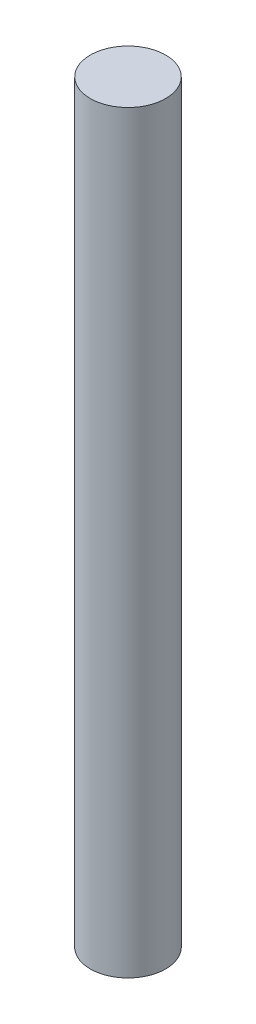
from build123d import *

# Parameters (mm, degrees)
SKETCH1_R           = 20
BOSS_EXTRUDE1_DEPTH = 400
SCALE1_SCALE        = 0.125


with BuildPart() as part:
    # Sketch1 → Boss-Extrude1 (new body)
    with BuildSketch(Plane(origin=(0, 0, 0), x_dir=(1, 0, 0), z_dir=(0, 1, 0))):
        Circle(SKETCH1_R)
    extrude(amount=BOSS_EXTRUDE1_DEPTH)


with BuildPart() as part_1:
    # Scale1: scaled about (0, 200, 0)
    add(part.part.scale(SCALE1_SCALE).moved(Location((0, 175, 0))))


solid = part_1.part
